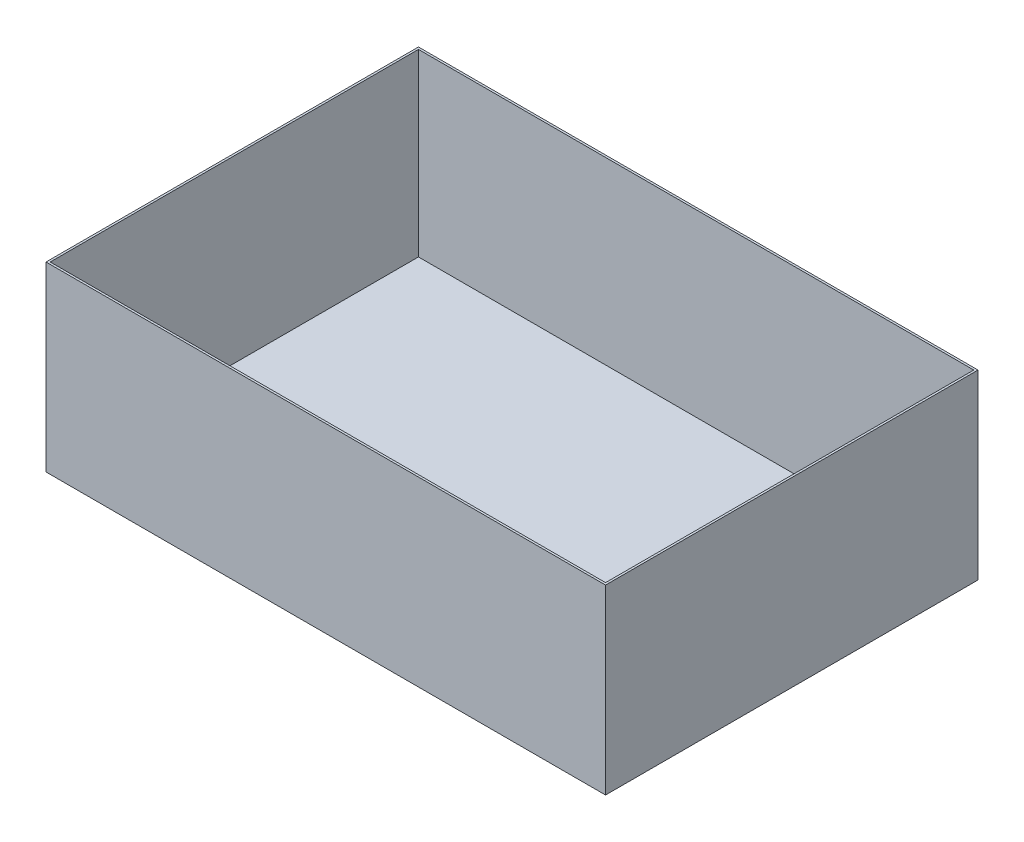
from build123d import *

# Parameters (mm, degrees)
SKETCH2_W           = 600
SKETCH2_H           = 399.38
BOSS_EXTRUDE1_DEPTH = 195
SHELL1_T            = -2.25


with BuildPart() as part:
    # Sketch2 → Boss-Extrude1 (new body)
    with BuildSketch(Plane(origin=(0, 0, 0), x_dir=(1, 0, 0), z_dir=(0, 1, 0))):
        with Locations((300, 199.69)):
            Rectangle(SKETCH2_W, SKETCH2_H)
    extrude(amount=BOSS_EXTRUDE1_DEPTH)

    # Shell1
    shell1_openings = [part.faces().sort_by_distance(p)[0] for p in [
        (300, 195, -199.69),
    ]]
    offset(amount=SHELL1_T, openings=shell1_openings, kind=Kind.INTERSECTION)


solid = part.part
